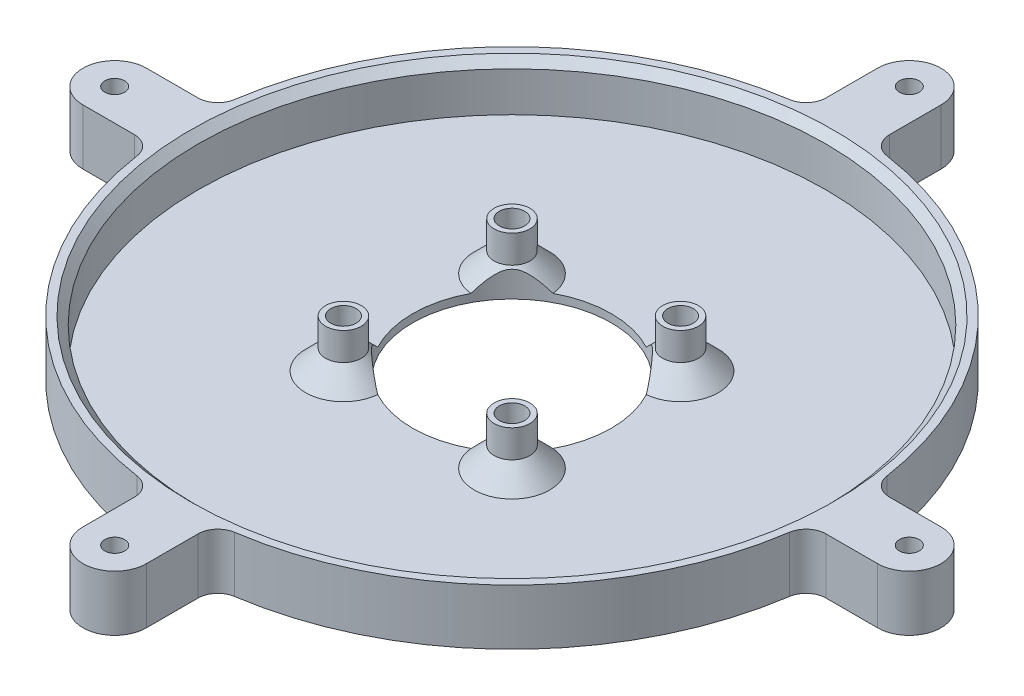
from build123d import *

# Parameters (mm, degrees)
SKETCH1_W                    = 8
SKETCH1_H                    = 8
BOSS_EXTRUDE1_DEPTH          = 7
SKETCH3_R                    = 39.5
CUT_EXTRUDE1_DEPTH           = 6
SKETCH5_R                    = 2.25
SKETCH5_R_2                  = 1.6
BOSS_EXTRUDE2_DEPTH          = 6
CHAMFER1_SIZE                = 2.5
CIRPATTERN1_COUNT            = 4
CHAMFER1_OF_CIRPATTERN1_SIZE = 2.5
SKETCH4_R                    = 12.5
CUT_EXTRUDE2_DEPTH           = 77.602872009
CUT_EXTRUDE2_DEPTH_BACK      = 77.602872009
M3X0_5_TAPPED_HOLE1_D        = 2.5
CHAMFER2_SIZE                = 1
FILLET1_R                    = 2.5
SKETCH8_R                    = 1.6
CUT_EXTRUDE3_DEPTH           = 77.602872009


with BuildPart() as part:
    # Sketch1 → Boss-Extrude1 (new body)
    with BuildSketch(Plane(origin=(0, 0, 0), x_dir=(1, 0, 0), z_dir=(0, 1, 0))):
        with BuildLine():
            Line((4, 41.306779105), (4, 50))
            ThreePointArc((4, 50), (0, 54), (-4, 50))
            Line((-4, 50), (-4, 41.306779105))
            ThreePointArc((-4, 41.306779105), (0, 41.5), (4, 41.306779105))
        make_face()
        with BuildLine():
            Line((50, 4), (41.306779105, 4))
            ThreePointArc((41.306779105, 4), (41.45166663, 2.002332035), (41.5, 0))
            ThreePointArc((41.5, 0), (41.45166663, -2.002332035), (41.306779105, -4))
            Line((41.306779105, -4), (50, -4))
            ThreePointArc((50, -4), (54, 0), (50, 4))
        make_face()
        with BuildLine():
            ThreePointArc((-41.306779105, -4), (-41.5, 0), (-41.306779105, 4))
            Line((-41.306779105, 4), (-50, 4))
            ThreePointArc((-50, 4), (-54, 0), (-50, -4))
            Line((-50, -4), (-41.306779105, -4))
        make_face()
        with BuildLine():
            Line((4, -50), (4, -41.306779105))
            ThreePointArc((4, -41.306779105), (0, -41.5), (-4, -41.306779105))
            Line((-4, -41.306779105), (-4, -50))
            ThreePointArc((-4, -50), (0, -54), (4, -50))
        make_face()
        with BuildLine():
            Line((41.306779105, -4), (4, -4))
            Line((4, -4), (4, -41.306779105))
            ThreePointArc((4, -41.306779105), (29.344931419, -29.344931419), (41.306779105, -4))
        make_face()
        with BuildLine():
            ThreePointArc((41.306779105, 4), (29.344931419, 29.344931419), (4, 41.306779105))
            Line((4, 41.306779105), (4, 4))
            Line((4, 4), (41.306779105, 4))
        make_face()
        with BuildLine():
            Line((-4, 4), (-4, 41.306779105))
            ThreePointArc((-4, 41.306779105), (-29.344931419, 29.344931419), (-41.306779105, 4))
            Line((-41.306779105, 4), (-4, 4))
        make_face()
        with BuildLine():
            Line((-4, -41.306779105), (-4, -4))
            Line((-4, -4), (-41.306779105, -4))
            ThreePointArc((-41.306779105, -4), (-29.344931419, -29.344931419), (-4, -41.306779105))
        make_face()
        with BuildLine():
            Line((41.306779105, 4), (4, 4))
            Line((4, 4), (4, -4))
            Line((4, -4), (41.306779105, -4))
            ThreePointArc((41.306779105, -4), (41.45166663, -2.002332035), (41.5, 0))
            ThreePointArc((41.5, 0), (41.45166663, 2.002332035), (41.306779105, 4))
        make_face()
        with BuildLine():
            Line((4, 4), (4, 41.306779105))
            ThreePointArc((4, 41.306779105), (0, 41.5), (-4, 41.306779105))
            Line((-4, 41.306779105), (-4, 4))
            Line((-4, 4), (4, 4))
        make_face()
        with BuildLine():
            Line((-4, -4), (-4, 4))
            Line((-4, 4), (-41.306779105, 4))
            ThreePointArc((-41.306779105, 4), (-41.5, 0), (-41.306779105, -4))
            Line((-41.306779105, -4), (-4, -4))
        make_face()
        with BuildLine():
            Line((4, -41.306779105), (4, -4))
            Line((4, -4), (-4, -4))
            Line((-4, -4), (-4, -41.306779105))
            ThreePointArc((-4, -41.306779105), (0, -41.5), (4, -41.306779105))
        make_face()
        Rectangle(SKETCH1_W, SKETCH1_H)
    extrude(amount=BOSS_EXTRUDE1_DEPTH)

    # Sketch3 → Cut-Extrude1 (cut)
    with BuildSketch(Plane(origin=(0, 7, 0), x_dir=(1, 0, 0), z_dir=(0, 1, 0))):
        with Locations(Location((0, 0, 0), (0, 0, 270))):
            Circle(SKETCH3_R)
    extrude(amount=-CUT_EXTRUDE1_DEPTH, mode=Mode.SUBTRACT)

    # Sketch5 → Boss-Extrude2 (add)
    with BuildSketch(Plane(origin=(0, 1, 0), x_dir=(1, 0, 0), z_dir=(0, 1, 0))):
        with Locations(Location((-10.606601718, 10.606601718, 0), (0, 0, 270))):
            Circle(SKETCH5_R)
        with Locations(Location((-10.606601718, 10.606601718, 0), (0, 0, 270))):
            Circle(SKETCH5_R_2, mode=Mode.SUBTRACT)
    boss_extrude2 = extrude(amount=BOSS_EXTRUDE2_DEPTH)

    # Chamfer1
    chamfer1_edges = [part.edges().sort_by_distance(p)[0] for p in [
        (-10.606601718, 1, -12.856601718),
    ]]
    chamfer(chamfer1_edges, length=CHAMFER1_SIZE)

    # CirPattern1: Boss-Extrude2 ×4 about axis
    cirpattern1_axis = Axis((0, 0, 0), (0, 1, 0))
    for i in range(1, CIRPATTERN1_COUNT):
        add(boss_extrude2.rotate(cirpattern1_axis, i * 360 / CIRPATTERN1_COUNT))

    # Chamfer1 of CirPattern1
    chamfer1_of_cirpattern1_edges = [part.edges().sort_by_distance(p)[0] for p in [
        (-12.856601718, 1, 10.606601718),
        (10.606601718, 1, 12.856601718),
        (12.856601718, 1, -10.606601718),
    ]]
    chamfer(chamfer1_of_cirpattern1_edges, length=CHAMFER1_OF_CIRPATTERN1_SIZE)

    # Sketch4 → Cut-Extrude2 (cut, two sides)
    with BuildSketch(Plane(origin=(0, 1, 0), x_dir=(1, 0, 0), z_dir=(0, 1, 0))) as cut_extrude2_sk:
        with Locations(Location((0, 0, 0), (0, 0, 270))):
            Circle(SKETCH4_R)
    extrude(amount=CUT_EXTRUDE2_DEPTH, mode=Mode.SUBTRACT)
    extrude(cut_extrude2_sk.sketch, amount=-CUT_EXTRUDE2_DEPTH_BACK, mode=Mode.SUBTRACT)

    # M3x0.5 Tapped Hole1 (through all)
    with Locations(Plane(origin=(0, 7, 0), x_dir=(1, 0, 0), z_dir=(0, 1, 0))):
        with Locations((0, 50), (50, 0), (-50, 0), (0, -50)):
            Hole(M3X0_5_TAPPED_HOLE1_D / 2)

    # Chamfer2
    chamfer2_edges = [part.edges().sort_by_distance(p)[0] for p in [
        (0, 7, -39.5),
    ]]
    chamfer(chamfer2_edges, length=CHAMFER2_SIZE)

    # Fillet1
    fillet1_edges = [part.edges().sort_by_distance(p)[0] for p in [
        (4, 3.5, 41.306779105),
        (-4, 3.5, 41.306779105),
        (-41.306779105, 3.5, 4),
        (-41.306779105, 3.5, -4),
        (-4, 3.5, -41.306779105),
        (4, 3.5, -41.306779105),
        (41.306779105, 3.5, -4),
        (41.306779105, 3.5, 4),
    ]]
    fillet(fillet1_edges, radius=FILLET1_R)

    # Sketch8 → Cut-Extrude3 (cut, through all)
    with BuildSketch(Plane(origin=(0, 1, 0), x_dir=(1, 0, 0), z_dir=(0, 1, 0))):
        with Locations(Location((10.606601718, 10.606601718, 0), (0, 0, 270))):
            Circle(SKETCH8_R)
        with Locations(Location((-10.606601718, 10.606601718, 0), (0, 0, 270))):
            Circle(SKETCH8_R)
        with Locations(Location((-10.606601718, -10.606601718, 0), (0, 0, 270))):
            Circle(SKETCH8_R)
        with Locations(Location((10.606601718, -10.606601718, 0), (0, 0, 270))):
            Circle(SKETCH8_R)
    extrude(amount=-CUT_EXTRUDE3_DEPTH, mode=Mode.SUBTRACT)


solid = part.part
